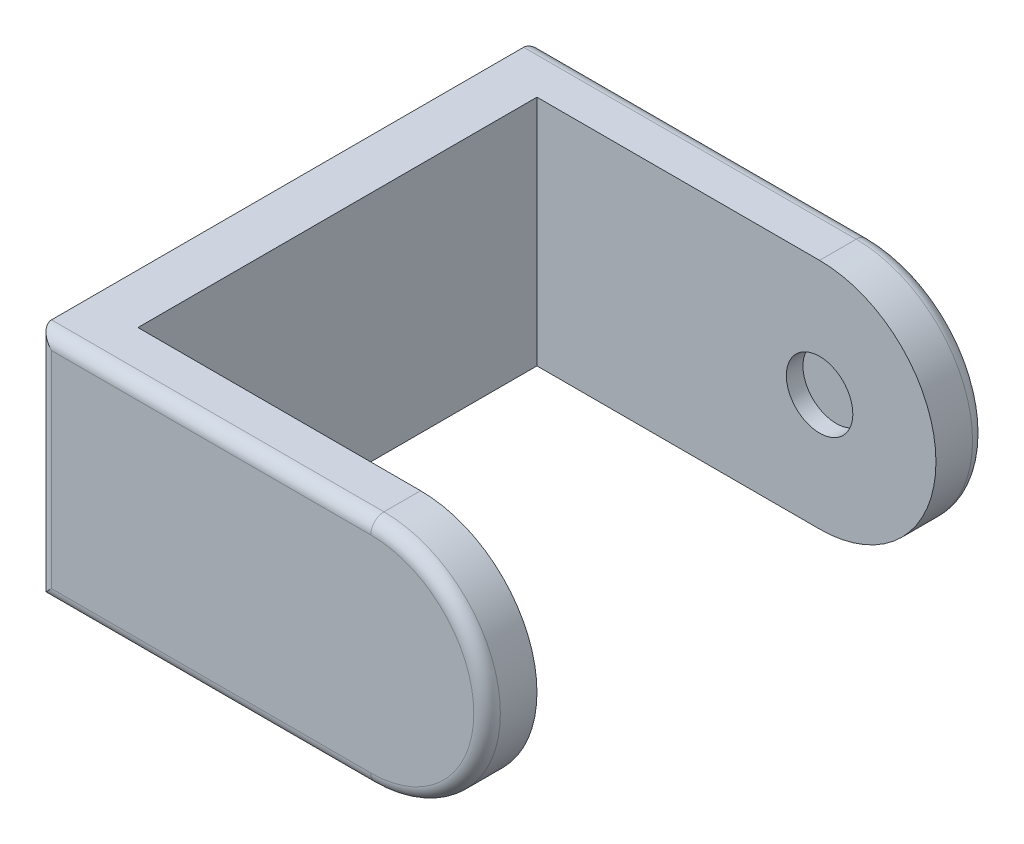
from build123d import *

# Parameters (mm, degrees)
SKETCH1_W               = 150
SKETCH1_H               = 70
BOSS_EXTRUDE1_DEPTH     = 15
SKETCH2_W               = 15
SKETCH2_H               = 70
BOSS_EXTRUDE2_DEPTH     = 120
CUT_EXTRUDE1_DEPTH      = 151
SKETCH5_R               = 10
CUT_EXTRUDE2_DEPTH      = 125
CUT_EXTRUDE2_DEPTH_BACK = 5
FILLET1_R               = 4
SKETCH6_R               = 15
CUT_EXTRUDE3_DEPTH      = 5


with BuildPart() as part:
    # Sketch1 → Boss-Extrude1 (new body)
    with BuildSketch(Plane(origin=(0, 0, 0), x_dir=(0, 0, -1), z_dir=(1, 0, 0))):
        Rectangle(SKETCH1_W, SKETCH1_H)
    extrude(amount=BOSS_EXTRUDE1_DEPTH)

    # Sketch2 → Boss-Extrude2 (add)
    with BuildSketch(Plane(origin=(15, 0, 0), x_dir=(0, 0, -1), z_dir=(1, 0, 0))):
        with Locations((-67.5, 0)):
            Rectangle(SKETCH2_W, SKETCH2_H)
        with Locations((67.5, 0)):
            Rectangle(SKETCH2_W, SKETCH2_H)
    extrude(amount=BOSS_EXTRUDE2_DEPTH)

    # Sketch3 → Cut-Extrude1 (cut, through all)
    with BuildSketch(Plane.XY.offset(75)):
        with BuildLine():
            ThreePointArc((99.999999969, 35), (124.748737331, 24.748737352), (135, 0))
            Line((135, 0), (135, 35))
            Line((135, 35), (99.999999969, 35))
        make_face()
        with BuildLine():
            Line((100, -35), (135, -35))
            Line((135, -35), (135, 0))
            ThreePointArc((135, 0), (124.748737342, -24.748737342), (100, -35))
        make_face()
    extrude(amount=-CUT_EXTRUDE1_DEPTH, mode=Mode.SUBTRACT)

    # Sketch5 → Cut-Extrude2 (cut, two sides)
    with BuildSketch(Plane(origin=(0, 0, 60), x_dir=(-1, 0, 0), z_dir=(0, 0, -1))) as cut_extrude2_sk:
        with Locations((-100, 0)):
            Circle(SKETCH5_R)
    extrude(amount=CUT_EXTRUDE2_DEPTH, mode=Mode.SUBTRACT)
    extrude(cut_extrude2_sk.sketch, amount=-CUT_EXTRUDE2_DEPTH_BACK, mode=Mode.SUBTRACT)

    # Fillet1
    fillet1_edges = [part.edges().sort_by_distance(p)[0] for p in [
        (49.999999985, 35, 75),
        (49.999999985, 35, -75),
        (135, 1.5e-08, 75),
        (135, 1.5e-08, -75),
        (0, 0, 75),
        (50, -35, -75),
        (50, -35, 75),
        (0, 0, -75),
    ]]
    fillet(fillet1_edges, radius=FILLET1_R)

    # Sketch6 → Cut-Extrude3 (cut)
    with BuildSketch(Plane.ZY):
        Circle(SKETCH6_R)
    extrude(amount=-CUT_EXTRUDE3_DEPTH, mode=Mode.SUBTRACT)


solid = part.part
